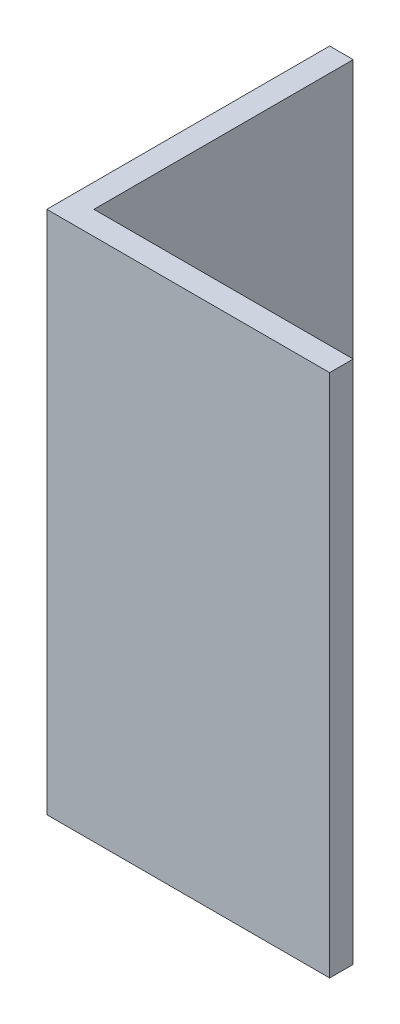
from build123d import *

# Parameters (mm, degrees)
BOSS_EXTRUDE1_DEPTH = 70.612


with BuildPart() as part:
    # Sketch1 → Boss-Extrude1 (new body)
    with BuildSketch(Plane(origin=(0, 0, 0), x_dir=(1, 0, 0), z_dir=(0, 1, 0))):
        Polygon((-30.994047619, 20.939880952), (-30.994047619, -17.160119048), (7.105952381, -17.160119048), (7.105952381, -13.985119048), (-27.819047619, -13.985119048), (-27.819047619, 20.939880952), align=None)
    extrude(amount=BOSS_EXTRUDE1_DEPTH)


solid = part.part
